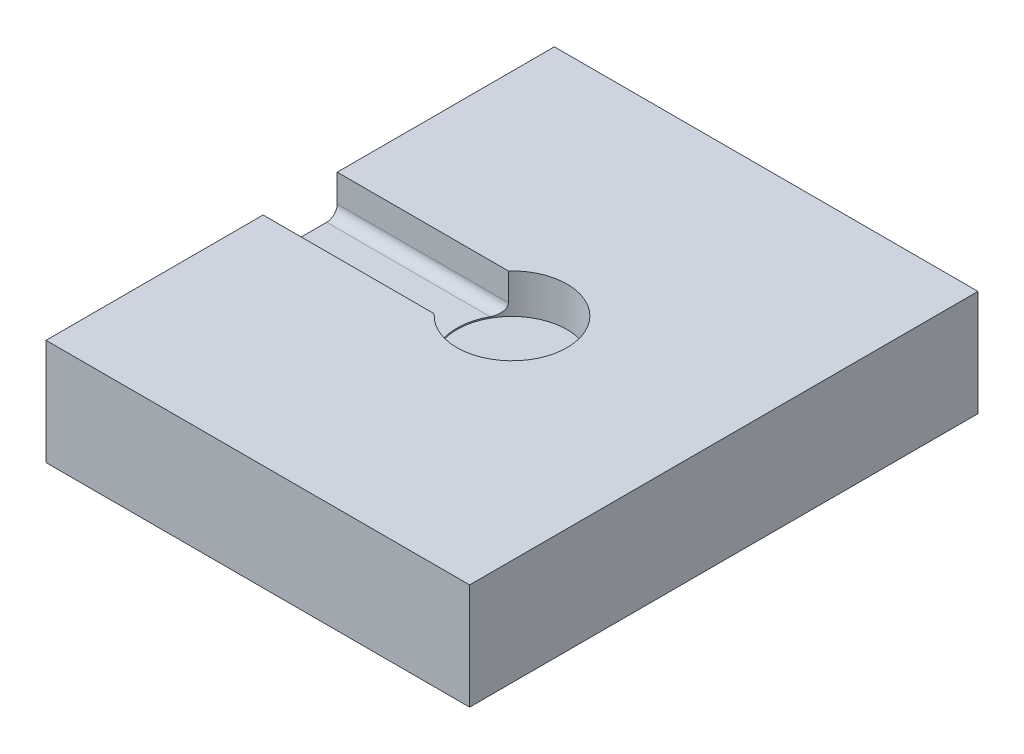
from build123d import *

# Parameters (mm, degrees)
SKETCH1_W           = 200
SKETCH1_H           = 240
BASE_DEPTH          = 50
SKETCH2_R           = 26
LOAD_CELL_CUT_DEPTH = 18.6
WIRE_CUT_REACH      = 202
SKETCH3_W           = 35
SKETCH3_H           = 18
WIRE_CUT_FILLET_R   = 5


with BuildPart() as part:
    # Sketch1 → base (new body)
    with BuildSketch(Plane(origin=(0, 0, 0), x_dir=(1, 0, 0), z_dir=(0, 1, 0))):
        Rectangle(SKETCH1_W, SKETCH1_H)
    extrude(amount=BASE_DEPTH)

    # Sketch2 → load cell cut (cut)
    with BuildSketch(Plane(origin=(0, 50, 0), x_dir=(1, 0, 0), z_dir=(0, 1, 0))):
        Circle(SKETCH2_R)
    extrude(amount=-LOAD_CELL_CUT_DEPTH, mode=Mode.SUBTRACT)

    # Sketch3 → wire cut (cut, up to next)
    with BuildSketch(Plane(origin=(-100, 0, 0), x_dir=(0, 0, -1), z_dir=(1, 0, 0)), mode=Mode.PRIVATE) as wire_cut_sk1:
        with Locations((0, 41)):
            Rectangle(SKETCH3_W, SKETCH3_H)
    wire_cut_tool1 = extrude(wire_cut_sk1.sketch, amount=WIRE_CUT_REACH, mode=Mode.PRIVATE) & part.part
    add(wire_cut_tool1.solids().sort_by_distance((-100, 41, 0))[0], mode=Mode.SUBTRACT)

    # wire cut fillet
    wire_cut_fillet_edges = [part.edges().sort_by_distance(p)[0] for p in [
        (-59.614442262, 32, -17.5),
        (-59.614442262, 32, 17.5),
    ]]
    fillet(wire_cut_fillet_edges, radius=WIRE_CUT_FILLET_R)


solid = part.part
